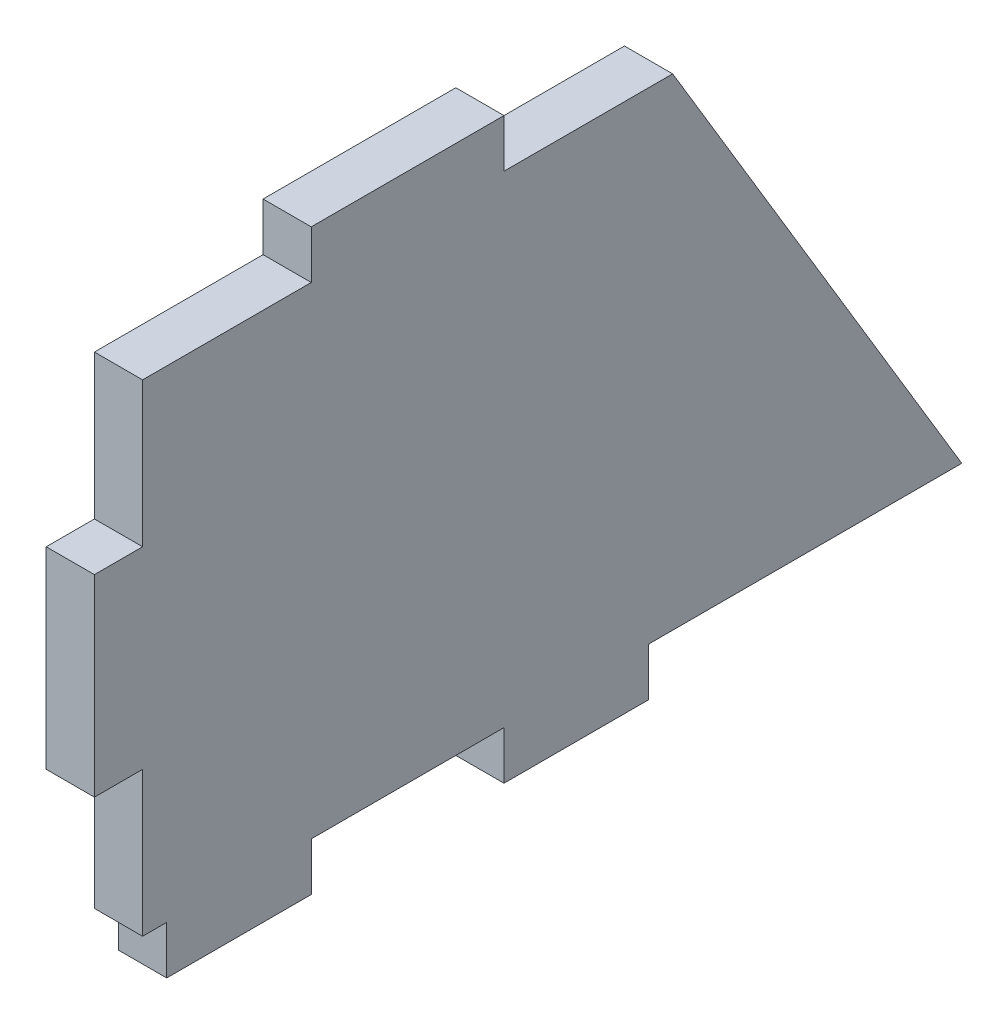
from build123d import *

# Parameters (mm, degrees)
BOSS_EXTRU_1_DEPTH = 5


with BuildPart() as part:
    # Esquisse1 → Boss.-Extru.1 (new body)
    with BuildSketch(Plane(origin=(0, 0, 0), x_dir=(0, 0, -1), z_dir=(1, 0, 0))):
        Polygon((55, 0), (85, -50), (52.5, -50), (52.5, -55), (37.5, -55), (37.5, -50), (17.5, -50), (17.5, -55), (2.5, -55), (2.5, -50), (0, -50), (0, -35), (-5, -35), (-5, -15), (0, -15), (0, 0), (17.5, 0), (17.5, 5), (37.5, 5), (37.5, 0), align=None)
    extrude(amount=BOSS_EXTRU_1_DEPTH)


solid = part.part
